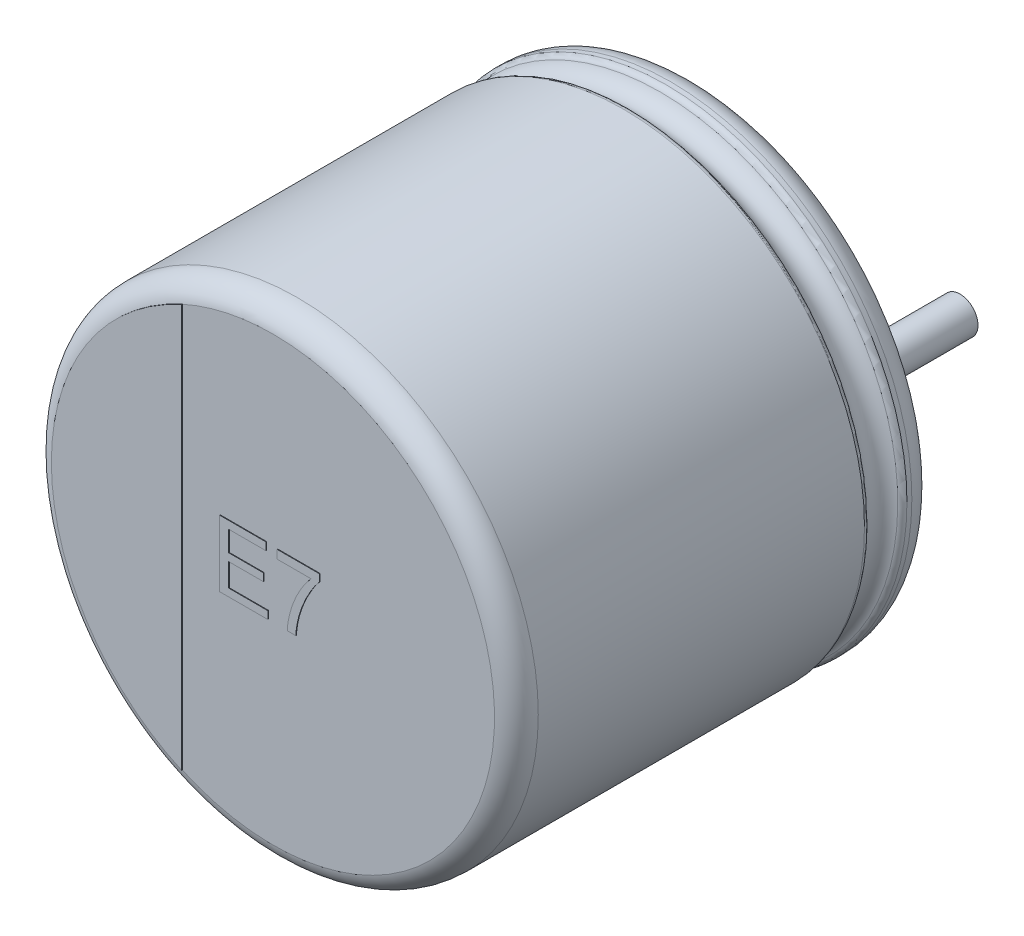
from build123d import *

# Parameters (mm, degrees)
SKETCH_2_R         = 0.3
EXTRUDE_1_DEPTH    = 2.7
EXTRUDE_2_DEPTH    = 0.01
EXTRUDE_1781_DEPTH = 0.01
EXTRUDE_5_DEPTH    = 0.05


with BuildPart() as part:
    # Sketch10 → Повернуть1 (revolve)
    with BuildSketch(Plane(origin=(0, 0, 0), x_dir=(0, 0, -1), z_dir=(1, 0, 0))):
        with BuildLine():
            Line((-7, 0), (-0.05, 0))
            Line((-0.05, 0), (-0.05, 3.403143426))
            ThreePointArc((-0.05, 3.403143426), (-0.052704561, 3.801565585), (-0.398206102, 4))
            Line((-0.398206102, 4), (-0.479422929, 4))
            ThreePointArc((-0.479422929, 4), (-0.534479696, 3.983479053), (-0.571344666, 3.939375046))
            ThreePointArc((-0.571344666, 3.939375046), (-0.831990181, 3.767472047), (-1.092635697, 3.939375046))
            ThreePointArc((-1.092635697, 3.939375046), (-1.129500666, 3.983479053), (-1.184557434, 4))
            Line((-1.184557434, 4), (-6.6, 4))
            ThreePointArc((-6.6, 4), (-6.85971595, 3.909961924), (-7, 3.67357323))
            Line((-7, 3.67357323), (-7, 0))
        make_face()
    revolve(axis=Axis((0, 0, -18.1630778), (0, 0, 1)))

    # Эскиз2 → Бобышка-Вытянуть1 (add)
    with BuildSketch(Plane(origin=(0, 0, 0.05), x_dir=(-1, 0, 0), z_dir=(0, 0, -1))):
        with Locations((-1.75, 0)):
            Circle(SKETCH_2_R)
        with Locations((1.75, 0)):
            Circle(SKETCH_2_R)
    extrude(amount=EXTRUDE_1_DEPTH)

    # Эскиз4 → Бобышка-Вытянуть2 (add)
    with BuildSketch(Plane.XY.offset(7)):
        with BuildLine():
            Line((-1.509635526, -3.349050739), (-1.509635526, 3.349050739))
            ThreePointArc((-1.509635526, 3.349050739), (-3.67357323, 0), (-1.509635526, -3.349050739))
        make_face()
    extrude(amount=EXTRUDE_2_DEPTH)

    # Эскиз5 → Extrude 1781 (add)
    with BuildSketch(Plane.XY.offset(7)):
        Polygon((-0.884369756, -0.464160183), (-0.884369756, 0.635839817), (-0.108728731, 0.635839817), (-0.108728731, 0.50891674), (-0.729241551, 0.50891674), (-0.729241551, 0.170455202), (-0.151036423, 0.170455202), (-0.151036423, 0.043532125), (-0.729241551, 0.043532125), (-0.729241551, -0.337237106), (-0.080523602, -0.337237106), (-0.080523602, -0.464160183), align=None)
        with BuildLine():
            Line((0.074604603, 0.480711612), (0.074604603, 0.621737253))
            Line((0.074604603, 0.621737253), (0.779732808, 0.621737253))
            Line((0.779732808, 0.621737253), (0.779732808, 0.507594625))
            add(Edge.make_bspline(
                [(0.779732808, 0.507594625), (0.771431609, 0.497887067), (0.754458572, 0.47803852), (0.729869663, 0.446422972), (0.705152985, 0.412763201), (0.680742985, 0.376735536), (0.656274929, 0.338602905), (0.631847292, 0.298243521), (0.607360353, 0.255755686), (0.575240818, 0.196264437), (0.536920557, 0.120100639), (0.497102168, 0.026253133), (0.46175264, -0.068529759), (0.442941226, -0.132991236), (0.43355893, -0.165141753)],
                knots=[0, 0, 0, 0, 3.8314e-05, 7.8339e-05, 0.000120121, 0.000163575, 0.000208868, 0.000256031, 0.000305091, 0.000355968, 0.000458848, 0.000560724, 0.00066167, 0.000762114, 0.000762114, 0.000762114, 0.000762114], degree=3))
            add(Edge.make_bspline(
                [(0.43355893, -0.165141753), (0.427474112, -0.188360883), (0.415095334, -0.235597214), (0.401544385, -0.308949256), (0.391067491, -0.385429808), (0.386953408, -0.437617745), (0.384861013, -0.464160183)],
                knots=[0, 0, 0, 0, 7.1988e-05, 0.000146451, 0.000223611, 0.00030347, 0.00030347, 0.00030347, 0.00030347], degree=3))
            Line((0.384861013, -0.464160183), (0.243835372, -0.464160183))
            add(Edge.make_bspline(
                [(0.243835372, -0.464160183), (0.24417363, -0.45321024), (0.244869239, -0.430692327), (0.247945276, -0.396091158), (0.252042276, -0.359770578), (0.25782894, -0.321853285), (0.265184267, -0.282262313), (0.273949101, -0.240955726), (0.284416876, -0.198018954), (0.29989812, -0.138489937), (0.322890283, -0.06363711), (0.356365208, 0.024869493), (0.394862276, 0.111857321), (0.431604744, 0.182399841), (0.462937079, 0.237332726), (0.486713979, 0.277190771), (0.511167015, 0.315171073), (0.535842849, 0.351546853), (0.560745759, 0.386348745), (0.586383028, 0.419251445), (0.611998782, 0.450915965), (0.629882886, 0.470867319), (0.638707167, 0.480711612)],
                knots=[0, 0, 0, 0, 3.2859e-05, 6.7573e-05, 0.000104171, 0.000142503, 0.00018261, 0.000224964, 0.000269163, 0.000315181, 0.000409485, 0.000503903, 0.000598901, 0.000694696, 0.000742362, 0.000788617, 0.00083391, 0.000877853, 0.000920478, 0.000962261, 0.001002975, 0.00104263, 0.00104263, 0.00104263, 0.00104263], degree=3))
            Line((0.638707167, 0.480711612), (0.074604603, 0.480711612))
        make_face()
    extrude(amount=EXTRUDE_1781_DEPTH)

    # Эскиз6 → Бобышка-Вытянуть5 (add)
    with BuildSketch(Plane(origin=(0, 0, 0.05), x_dir=(-1, 0, 0), z_dir=(0, 0, -1))):
        with BuildLine():
            Line((-1.75, 0.465643654), (-2.133155916, 0.465643654))
            ThreePointArc((-2.133155916, 0.465643654), (-2.336107869, 0.569662474), (-2.37017324, 0.795159615))
            ThreePointArc((-2.37017324, 0.795159615), (0, 2.5), (2.37017324, 0.795159615))
            ThreePointArc((2.37017324, 0.795159615), (2.336107869, 0.569662474), (2.133155916, 0.465643654))
            Line((2.133155916, 0.465643654), (1.75, 0.465643654))
            ThreePointArc((1.75, 0.465643654), (1.284356346, 0), (1.75, -0.465643654))
            Line((1.75, -0.465643654), (2.133155916, -0.465643654))
            ThreePointArc((2.133155916, -0.465643654), (2.336107869, -0.569662474), (2.37017324, -0.795159615))
            ThreePointArc((2.37017324, -0.795159615), (0, -2.5), (-2.37017324, -0.795159615))
            ThreePointArc((-2.37017324, -0.795159615), (-2.336107869, -0.569662474), (-2.133155916, -0.465643654))
            Line((-2.133155916, -0.465643654), (-1.75, -0.465643654))
            ThreePointArc((-1.75, -0.465643654), (-1.284356346, 0), (-1.75, 0.465643654))
        make_face()
    extrude(amount=EXTRUDE_5_DEPTH)


solid = part.part
